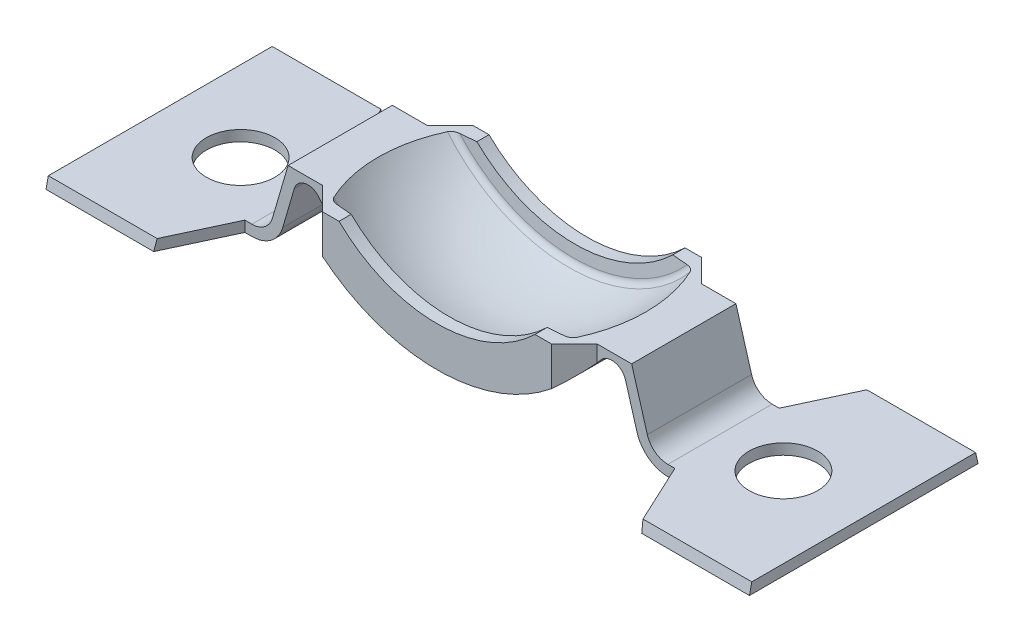
from build123d import *

# Parameters (mm, degrees)
SALIENTE_EXTRUIR1_DEPTH      = 16
SALIENTE_EXTRUIR1_DEPTH_BACK = 16
CORTAR_EXTRUIR1_DEPTH        = 49.25
CORTAR_EXTRUIR1_DEPTH_BACK   = 49.25
CROQUIS3_R                   = 4.8
CORTAR_EXTRUIR2_DEPTH        = 25.3
CROQUIS4_R                   = 4.8
CORTAR_EXTRUIR3_DEPTH        = 25.3
CORTAR_EXTRUIR4_DEPTH        = 98.5
CORTAR_EXTRUIR4_DEPTH_BACK   = 98.5
CROQUIS6_W                   = 64
CROQUIS6_H                   = 50.5
CROQUIS7_W                   = 118.5
CROQUIS7_H                   = 52
CORTAR_EXTRUIR5_DEPTH        = 25.3


with BuildPart() as part:
    # Croquis1 → Saliente-Extruir1 (new, two sides: drawn at the far end of the back side and taken through both)
    with BuildSketch(Plane.XY.offset(-SALIENTE_EXTRUIR1_DEPTH_BACK)):
        with BuildLine():
            Line((-49.25, -23.8), (-49.25, -25.3))
            Line((-49.25, -25.3), (-29.12605042, -25.3))
            ThreePointArc((-29.12605042, -25.3), (-26.427107301, -24.400792418), (-24.806790899, -22.062536016))
            Line((-24.806790899, -22.062536016), (-23.194455177, -16.5465774))
            ThreePointArc((-23.194455177, -16.5465774), (-21.665135808, -15.146167956), (-19.716192024, -15.854392832))
            ThreePointArc((-19.716192024, -15.854392832), (0, -25.3), (19.716192024, -15.854392832))
            ThreePointArc((19.716192024, -15.854392832), (21.665135808, -15.146167956), (23.194455177, -16.5465774))
            Line((23.194455177, -16.5465774), (24.806790899, -22.062536016))
            ThreePointArc((24.806790899, -22.062536016), (26.427107301, -24.400792418), (29.12605042, -25.3))
            Line((29.12605042, -25.3), (49.25, -25.3))
            Line((49.25, -25.3), (49.25, -23.8))
            Line((49.25, -23.8), (29.12605042, -23.8))
            ThreePointArc((29.12605042, -23.8), (27.326755007, -23.200528279), (26.246544073, -21.641690678))
            Line((26.246544073, -21.641690678), (22.185653478, -7.748985725))
            ThreePointArc((22.185653478, -7.748985725), (0, -23.5), (-22.185653478, -7.748985725))
            Line((-22.185653478, -7.748985725), (-26.246544073, -21.641690678))
            ThreePointArc((-26.246544073, -21.641690678), (-27.326755007, -23.200528279), (-29.12605042, -23.8))
            Line((-29.12605042, -23.8), (-49.25, -23.8))
        make_face()
    extrude(amount=SALIENTE_EXTRUIR1_DEPTH + SALIENTE_EXTRUIR1_DEPTH_BACK)

    # Croquis2 → Cortar-Extruir1 (cut, two sides: drawn at the far end of the back side and taken through both)
    with BuildSketch(Plane(origin=(0, 0, 0), x_dir=(0, 0, -1), z_dir=(1, 0, 0)).offset(-CORTAR_EXTRUIR1_DEPTH_BACK)):
        Polygon((-16, -25.3), (-10.5, 0), (-10.5, 25.2), (10.5, 25.2), (10.5, 0), (16, -25.3), (16, 26.2), (-16, 26.2), align=None)
    extrude(amount=CORTAR_EXTRUIR1_DEPTH + CORTAR_EXTRUIR1_DEPTH_BACK, mode=Mode.SUBTRACT)

    # Croquis3 → Cortar-Extruir2 (cut)
    with BuildSketch(Plane(origin=(0, 0, 0), x_dir=(1, 0, 0), z_dir=(0, 1, 0))):
        with Locations((38, 0)):
            Circle(CROQUIS3_R)
    extrude(amount=-CORTAR_EXTRUIR2_DEPTH, mode=Mode.SUBTRACT)

    # Croquis4 → Cortar-Extruir3 (cut)
    with BuildSketch(Plane(origin=(0, 0, 0), x_dir=(1, 0, 0), z_dir=(0, 1, 0))):
        with Locations((-38, 0)):
            Circle(CROQUIS4_R)
    extrude(amount=-CORTAR_EXTRUIR3_DEPTH, mode=Mode.SUBTRACT)

    # Croquis5 → Revolución1 (revolve)
    with BuildSketch(Plane(origin=(0, 0, 0), x_dir=(0, 0, -1), z_dir=(1, 0, 0))):
        with BuildLine():
            Line((-10.5, -19.709677419), (-10.5, -23.65))
            Line((-10.5, -23.65), (10.5, -23.65))
            Line((10.5, -23.65), (10.5, -19.709677419))
            Line((10.5, -19.709677419), (8.8, -19.709677419))
            Line((8.8, -19.709677419), (8.60641193, -21.293920434))
            ThreePointArc((8.60641193, -21.293920434), (8.395381567, -21.796423837), (7.952186088, -22.113632366))
            ThreePointArc((7.952186088, -22.113632366), (-4.5e-08, -23.5), (-7.952186172, -22.113632336))
            ThreePointArc((-7.952186172, -22.113632336), (-8.395381595, -21.796423802), (-8.60641193, -21.293920434))
            Line((-8.60641193, -21.293920434), (-8.8, -19.709677419))
            Line((-8.8, -19.709677419), (-10.5, -19.709677419))
        make_face()
    revolve(axis=Axis((0, 0, 16), (0, 0, -1)))

    # Croquis6 → Cortar-Extruir4 (cut, two sides: drawn at the far end of the back side and taken through both)
    with BuildSketch(Plane(origin=(0, 0, 0), x_dir=(0, 0, -1), z_dir=(1, 0, 0)).offset(-CORTAR_EXTRUIR4_DEPTH_BACK)):
        with Locations((0, 11.1)):
            Rectangle(CROQUIS6_W, CROQUIS6_H)
    extrude(amount=CORTAR_EXTRUIR4_DEPTH + CORTAR_EXTRUIR4_DEPTH_BACK, mode=Mode.SUBTRACT)

    # Croquis7 → Cortar-Extruir5 (cut)
    with BuildSketch(Plane(origin=(0, 0, 0), x_dir=(1, 0, 0), z_dir=(0, 1, 0))):
        Rectangle(CROQUIS7_W, CROQUIS7_H)
        Polygon((-49.25, 16), (-49.25, -16), (-34.16469212, -16), (-30.107815494, -7.3), (-19.2, -7.3), (-16, -10.5), (16, -10.5), (19.2, -7.3), (30.107815494, -7.3), (34.16469212, -16), (49.25, -16), (49.25, 16), (34.16469212, 16), (30.107815494, 7.3), (19.2, 7.3), (16, 10.5), (-16, 10.5), (-19.2, 7.3), (-30.107815494, 7.3), (-34.16469212, 16), align=None, mode=Mode.SUBTRACT)
    extrude(amount=-CORTAR_EXTRUIR5_DEPTH, mode=Mode.SUBTRACT)


solid = part.part
